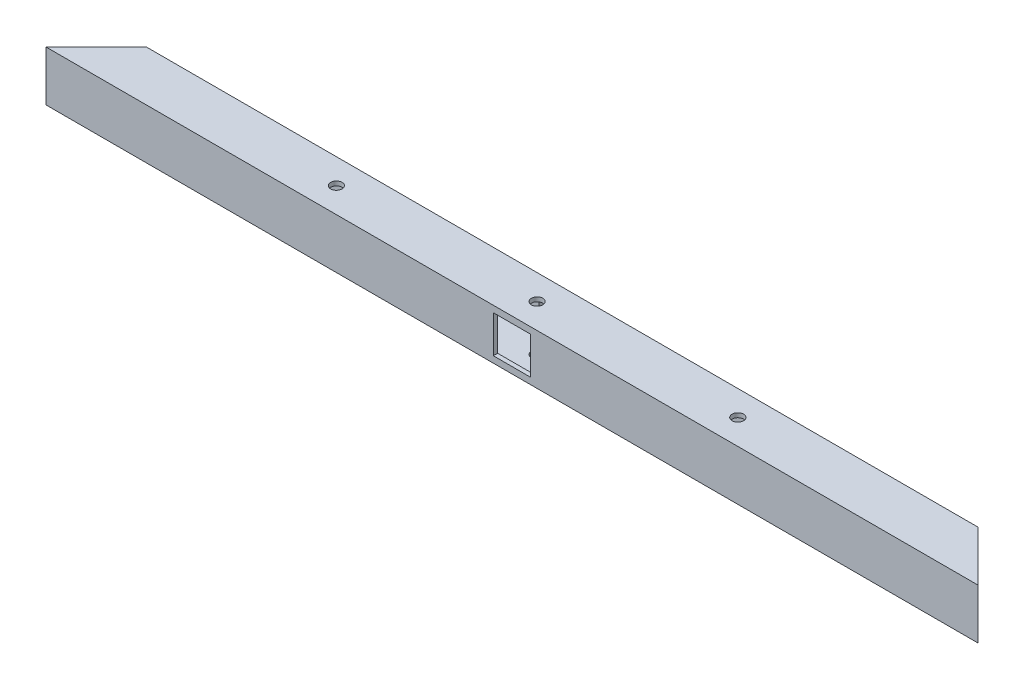
from build123d import *

# Parameters (mm, degrees)
BOSS_EXTRUDE1_DEPTH = 35
SHELL1_T            = -3
SKETCH2_W           = 26
SKETCH2_H           = 26
CUT_EXTRUDE1_DEPTH  = 36
SKETCH3_R           = 4
CUT_EXTRUDE2_DEPTH  = 36


with BuildPart() as part:
    # Sketch1 → Boss-Extrude1 (new body)
    with BuildSketch(Plane(origin=(0, 0, 0), x_dir=(1, 0, 0), z_dir=(0, 1, 0))):
        Polygon((-325, -12.5), (-290, 22.5), (290, 22.5), (325, -12.5), align=None)
    extrude(amount=BOSS_EXTRUDE1_DEPTH)

    # Shell1
    shell1_openings = [part.faces().sort_by_distance(p)[0] for p in [
        (-307.5, 17.5, -5),
        (307.5, 17.5, -5),
    ]]
    offset(amount=SHELL1_T, openings=shell1_openings, kind=Kind.INTERSECTION)

    # Sketch2 → Cut-Extrude1 (cut, through all)
    with BuildSketch(Plane.XY.offset(12.5)):
        with Locations((0, 17.5)):
            Rectangle(SKETCH2_W, SKETCH2_H)
    extrude(amount=-CUT_EXTRUDE1_DEPTH, mode=Mode.SUBTRACT)

    # Sketch3 → Cut-Extrude2 (cut, through all)
    with BuildSketch(Plane(origin=(0, 35, 0), x_dir=(1, 0, 0), z_dir=(0, 1, 0))):
        with Locations((0, 5)):
            Circle(SKETCH3_R)
        with Locations((140, 5)):
            Circle(SKETCH3_R)
        with Locations((-140, 5)):
            Circle(SKETCH3_R)
    extrude(amount=-CUT_EXTRUDE2_DEPTH, mode=Mode.SUBTRACT)


solid = part.part
